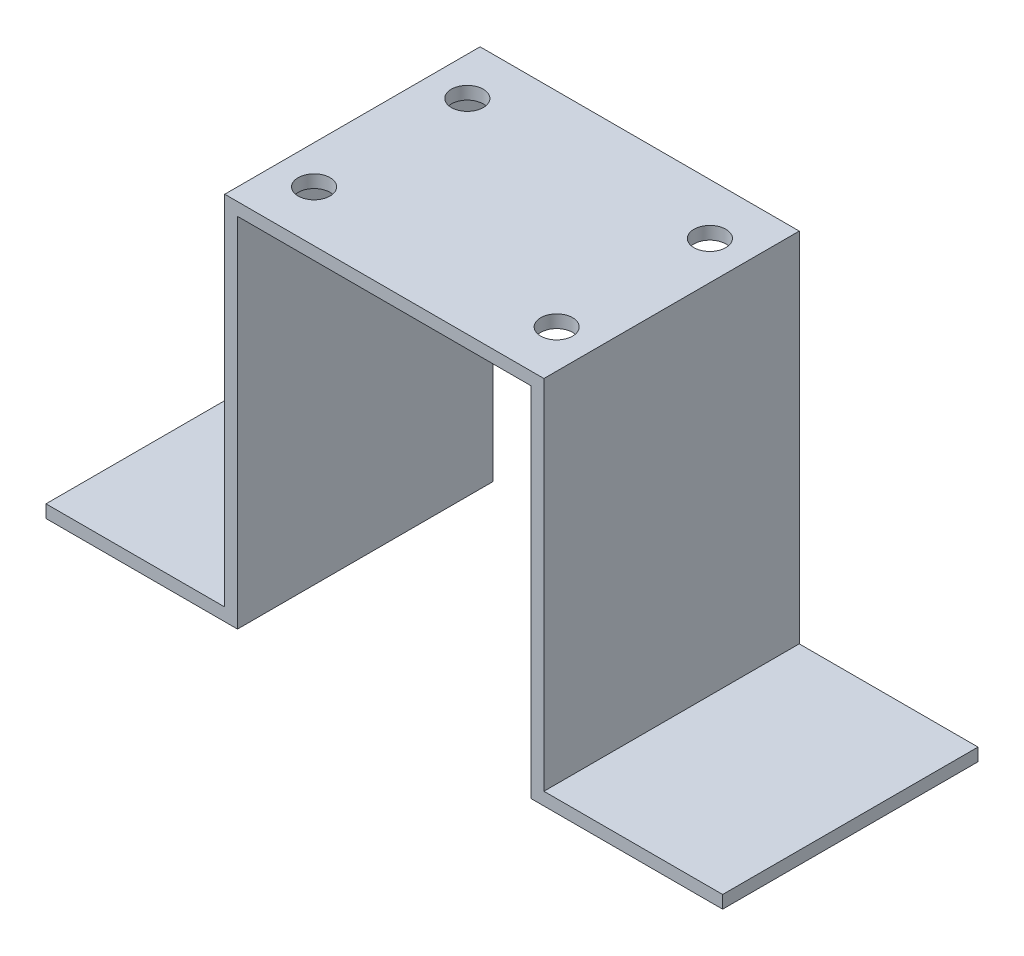
from build123d import *

# Parameters (mm, degrees)
BOSS_EXTRUDE1_DEPTH = 50.8
CUT_EXTRUDE1_REACH  = 75.66
SKETCH12_R          = 3.175


with BuildPart() as part:
    # Sketch11 → Boss-Extrude1 (new body)
    with BuildSketch(Plane.XY):
        Polygon((0, 0), (38.1, 0), (38.1, 71.12), (96.52, 71.12), (96.52, 0), (134.62, 0), (134.62, 2.54), (99.06, 2.54), (99.06, 73.66), (35.56, 73.66), (35.56, 2.54), (0, 2.54), align=None)
    extrude(amount=-BOSS_EXTRUDE1_DEPTH)

    # Sketch12 → Cut-Extrude1 (cut, up to next)
    with BuildSketch(Plane(origin=(0, 73.66, 0), x_dir=(1, 0, 0), z_dir=(0, 1, 0)), mode=Mode.PRIVATE) as cut_extrude1_sk1:
        with Locations((43.18, 10.16)):
            Circle(SKETCH12_R)
    cut_extrude1_tool1 = extrude(cut_extrude1_sk1.sketch, amount=-CUT_EXTRUDE1_REACH, mode=Mode.PRIVATE) & part.part
    add(cut_extrude1_tool1.solids().sort_by_distance((43.18, 73.66, -10.16))[0], mode=Mode.SUBTRACT)
    # Sketch12 → Cut-Extrude1 (cut, up to next)
    with BuildSketch(Plane(origin=(0, 73.66, 0), x_dir=(1, 0, 0), z_dir=(0, 1, 0)), mode=Mode.PRIVATE) as cut_extrude1_sk2:
        with Locations((91.44, 10.16)):
            Circle(SKETCH12_R)
    cut_extrude1_tool2 = extrude(cut_extrude1_sk2.sketch, amount=-CUT_EXTRUDE1_REACH, mode=Mode.PRIVATE) & part.part
    add(cut_extrude1_tool2.solids().sort_by_distance((91.44, 73.66, -10.16))[0], mode=Mode.SUBTRACT)
    # Sketch12 → Cut-Extrude1 (cut, up to next)
    with BuildSketch(Plane(origin=(0, 73.66, 0), x_dir=(1, 0, 0), z_dir=(0, 1, 0)), mode=Mode.PRIVATE) as cut_extrude1_sk3:
        with Locations((91.44, 40.64)):
            Circle(SKETCH12_R)
    cut_extrude1_tool3 = extrude(cut_extrude1_sk3.sketch, amount=-CUT_EXTRUDE1_REACH, mode=Mode.PRIVATE) & part.part
    add(cut_extrude1_tool3.solids().sort_by_distance((91.44, 73.66, -40.64))[0], mode=Mode.SUBTRACT)
    # Sketch12 → Cut-Extrude1 (cut, up to next)
    with BuildSketch(Plane(origin=(0, 73.66, 0), x_dir=(1, 0, 0), z_dir=(0, 1, 0)), mode=Mode.PRIVATE) as cut_extrude1_sk4:
        with Locations((43.18, 40.64)):
            Circle(SKETCH12_R)
    cut_extrude1_tool4 = extrude(cut_extrude1_sk4.sketch, amount=-CUT_EXTRUDE1_REACH, mode=Mode.PRIVATE) & part.part
    add(cut_extrude1_tool4.solids().sort_by_distance((43.18, 73.66, -40.64))[0], mode=Mode.SUBTRACT)


solid = part.part
